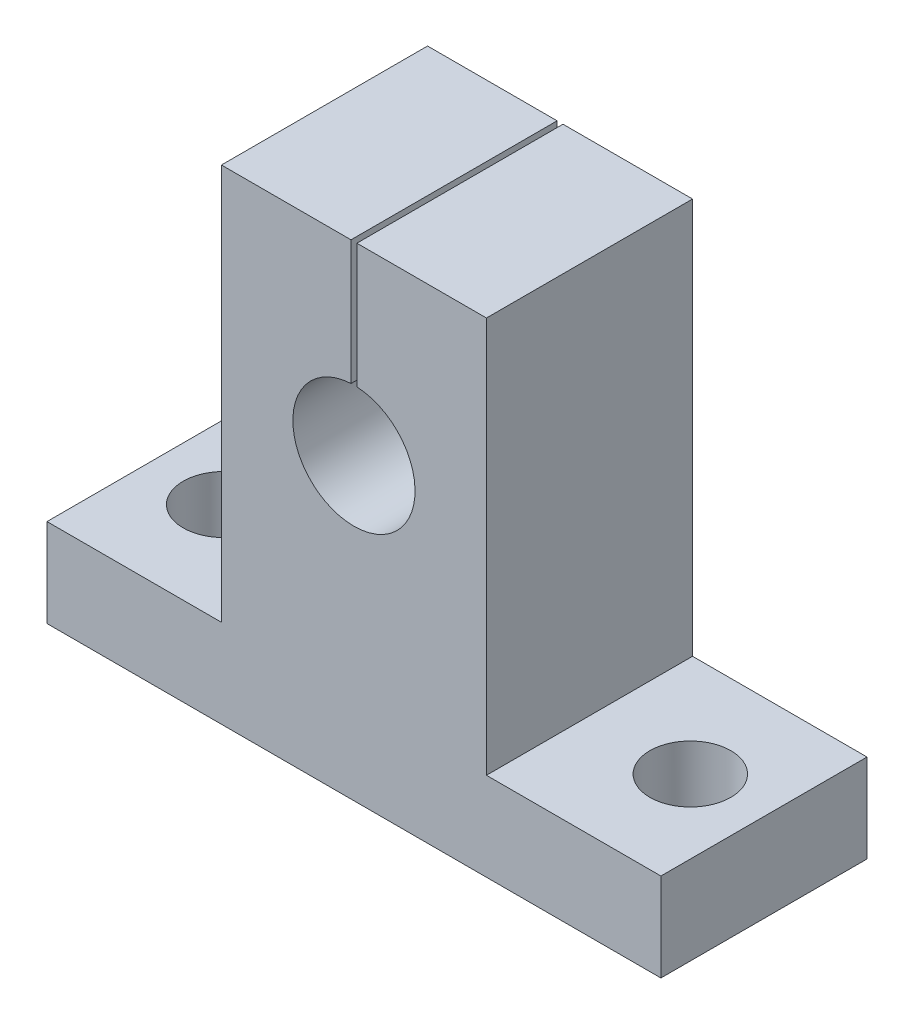
from build123d import *

# Parameters (mm, degrees)
BOSS_EXTRUDE1_DEPTH = 14
SKETCH2_R           = 2.75
CUT_EXTRUDE1_DEPTH  = 33.9


with BuildPart() as part:
    # Sketch1 → Boss-Extrude1 (new body)
    with BuildSketch(Plane.XY):
        with BuildLine():
            Line((-20.85, 6), (-20.85, 0))
            Line((-20.85, 0), (20.85, 0))
            Line((20.85, 0), (20.85, 6))
            Line((20.85, 6), (9, 6))
            Line((9, 6), (9, 32.9))
            Line((9, 32.9), (0.2, 32.9))
            Line((0.2, 32.9), (0.2, 24.445177921))
            ThreePointArc((0.2, 24.445177921), (3.004371815, 23.162909359), (4.15, 20.3))
            ThreePointArc((4.15, 20.3), (-2.862909359, 17.295628185), (-0.2, 24.445177921))
            Line((-0.2, 24.445177921), (-0.2, 32.9))
            Line((-0.2, 32.9), (-9, 32.9))
            Line((-9, 32.9), (-9, 6))
            Line((-9, 6), (-20.85, 6))
        make_face()
    extrude(amount=BOSS_EXTRUDE1_DEPTH)

    # Sketch2 → Cut-Extrude1 (cut, through all)
    with BuildSketch(Plane.XZ):
        with Locations((-15.85, 7)):
            Circle(SKETCH2_R)
        with Locations((15.85, 7)):
            Circle(SKETCH2_R)
    extrude(amount=-CUT_EXTRUDE1_DEPTH, mode=Mode.SUBTRACT)


solid = part.part
